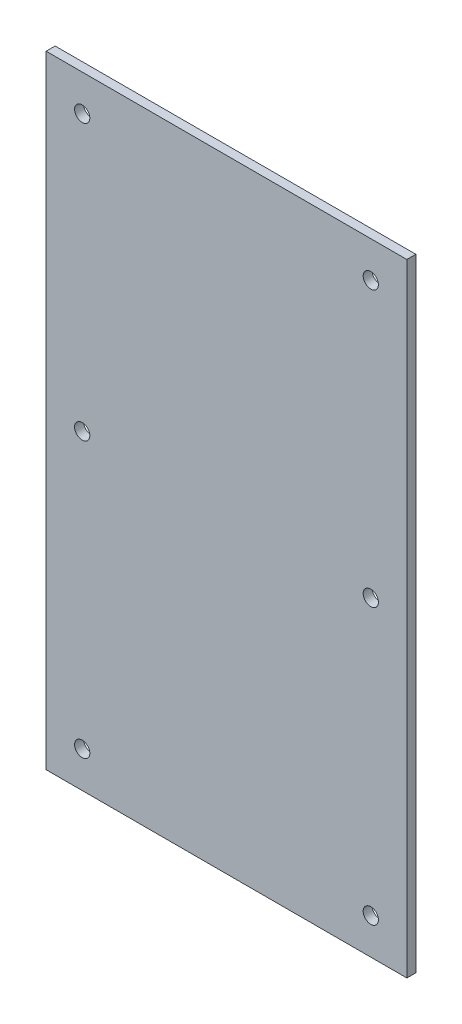
from build123d import *

# Parameters (mm, degrees)
SKETCH1_W                        = 254
SKETCH1_H                        = 438.15
BOSS_EXTRUDE1_DEPTH              = 6.35
F_27_64_0_42188_DIAMETER_HOLE1_D = 10.715752


with BuildPart() as part:
    # Sketch1 → Boss-Extrude1 (new body)
    with BuildSketch(Plane.XY):
        Rectangle(SKETCH1_W, SKETCH1_H)
    extrude(amount=BOSS_EXTRUDE1_DEPTH)

    # 27/64 (0.42188) Diameter Hole1 (through all)
    with Locations(Plane.XY.offset(6.35)):
        with Locations((-101.6, 193.675), (-101.6, 0), (-101.6, -193.675), (101.6, 193.675), (101.6, 0), (101.6, -193.675)):
            Hole(F_27_64_0_42188_DIAMETER_HOLE1_D / 2)


solid = part.part
